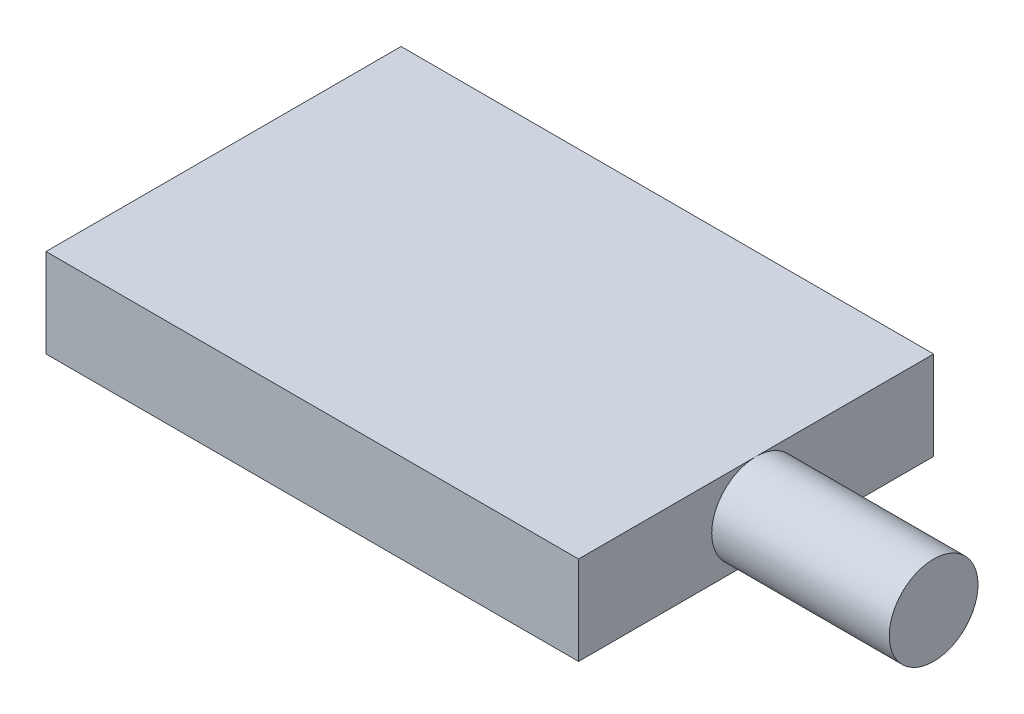
from build123d import *

# Parameters (mm, degrees)
SKETCH1_W           = 30
SKETCH1_H           = 20
BOSS_EXTRUDE1_DEPTH = 5
SKETCH2_R           = 2.5
BOSS_EXTRUDE2_DEPTH = 10


with BuildPart() as part:
    # Sketch1 → Boss-Extrude1 (new body)
    with BuildSketch(Plane(origin=(0, 0, 0), x_dir=(1, 0, 0), z_dir=(0, 1, 0))):
        with Locations((15, 10)):
            Rectangle(SKETCH1_W, SKETCH1_H)
    extrude(amount=BOSS_EXTRUDE1_DEPTH)

    # Sketch2 → Boss-Extrude2 (add)
    with BuildSketch(Plane(origin=(30, 0, 0), x_dir=(0, 0, -1), z_dir=(1, 0, 0))):
        with Locations((10, 2.5)):
            Circle(SKETCH2_R)
    extrude(amount=BOSS_EXTRUDE2_DEPTH)


solid = part.part
